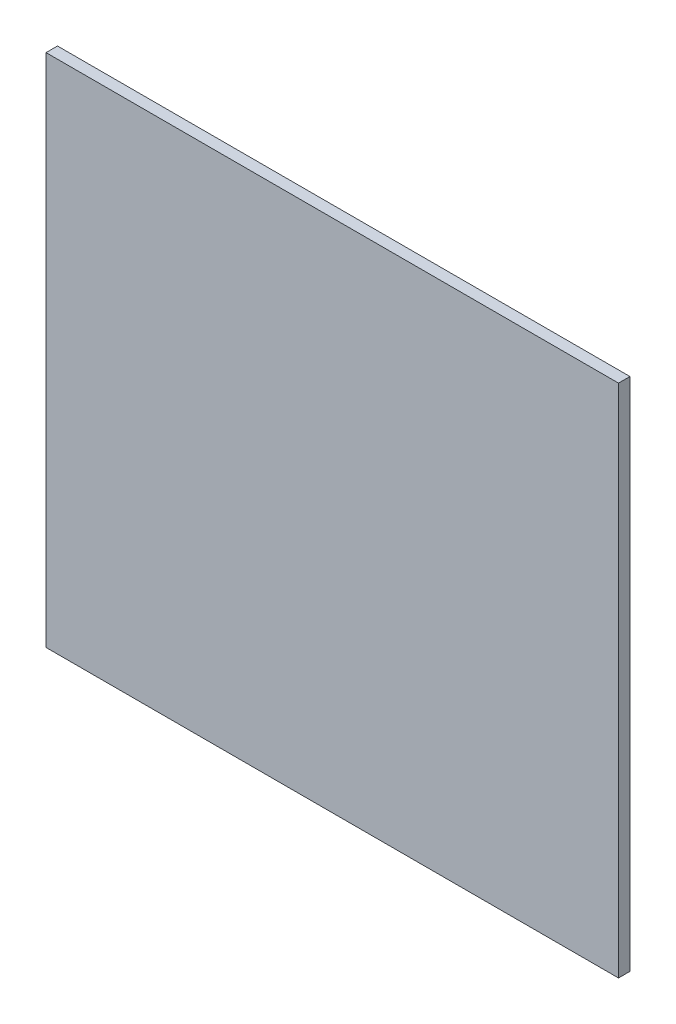
from build123d import *

# Parameters (mm, degrees)
SKETCH1_W           = 500
SKETCH1_H           = 450
BOSS_EXTRUDE1_DEPTH = 10


with BuildPart() as part:
    # Sketch1 → Boss-Extrude1 (new body)
    with BuildSketch(Plane.XY):
        Rectangle(SKETCH1_W, SKETCH1_H)
    extrude(amount=BOSS_EXTRUDE1_DEPTH)


solid = part.part
